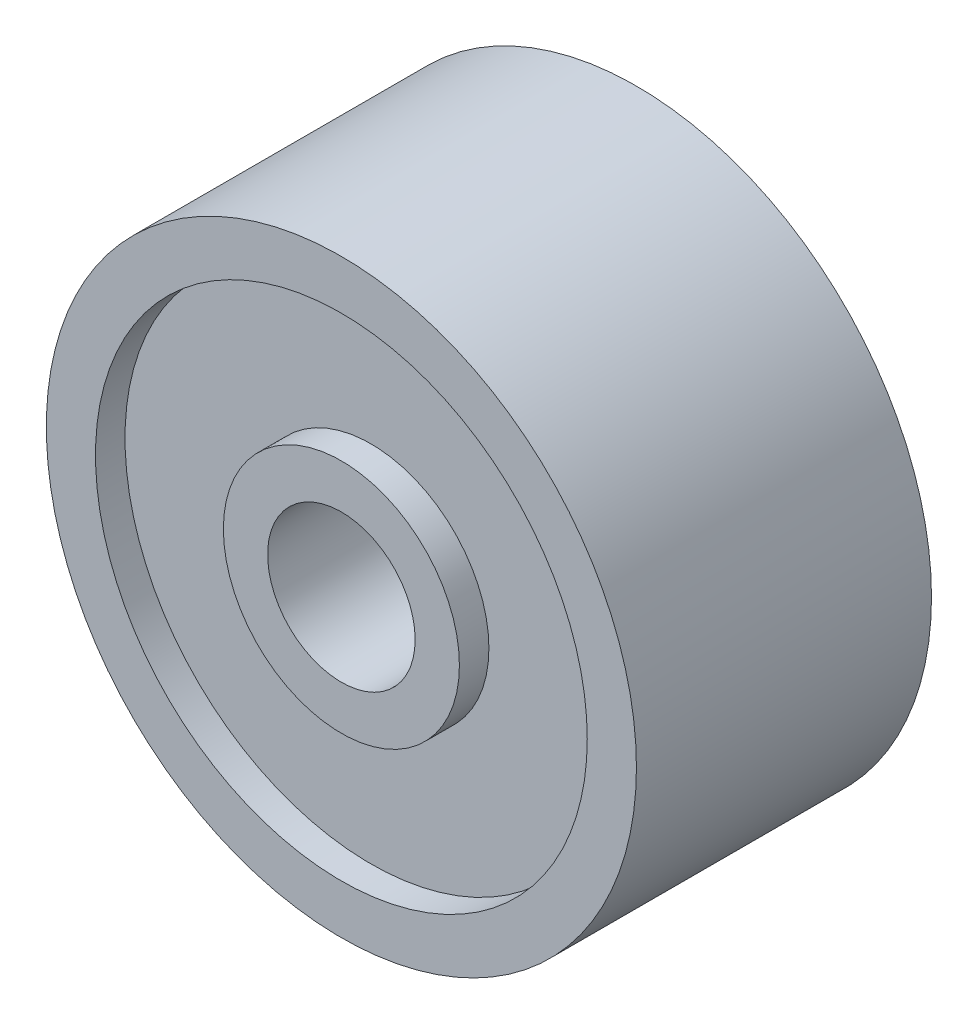
from build123d import *

# Parameters (mm, degrees)
SKETCH1_R           = 3
SKETCH1_R_2         = 0.75
BOSS_EXTRUDE1_DEPTH = 3
SKETCH2_R           = 2.5
SKETCH2_R_2         = 1.2
CUT_EXTRUDE1_DEPTH  = 0.3
CUT_EXTRUDE2_START  = -3
SKETCH2_2_R         = 2.5
SKETCH2_2_R_2       = 1.2
CUT_EXTRUDE2_DEPTH  = 0.3


with BuildPart() as part:
    # Sketch1 → Boss-Extrude1 (new body)
    with BuildSketch(Plane.XY):
        Circle(SKETCH1_R)
        Circle(SKETCH1_R_2, mode=Mode.SUBTRACT)
    extrude(amount=BOSS_EXTRUDE1_DEPTH)

    # Sketch2 → Cut-Extrude1 (cut)
    with BuildSketch(Plane.XY.offset(3)):
        Circle(SKETCH2_R)
        Circle(SKETCH2_R_2, mode=Mode.SUBTRACT)
    extrude(amount=-CUT_EXTRUDE1_DEPTH, mode=Mode.SUBTRACT)

    # Sketch2_2 → Cut-Extrude2 (cut)
    with BuildSketch(Plane.XY.offset(3).offset(CUT_EXTRUDE2_START)):
        Circle(SKETCH2_2_R)
        Circle(SKETCH2_2_R_2, mode=Mode.SUBTRACT)
    extrude(amount=CUT_EXTRUDE2_DEPTH, mode=Mode.SUBTRACT)


solid = part.part
